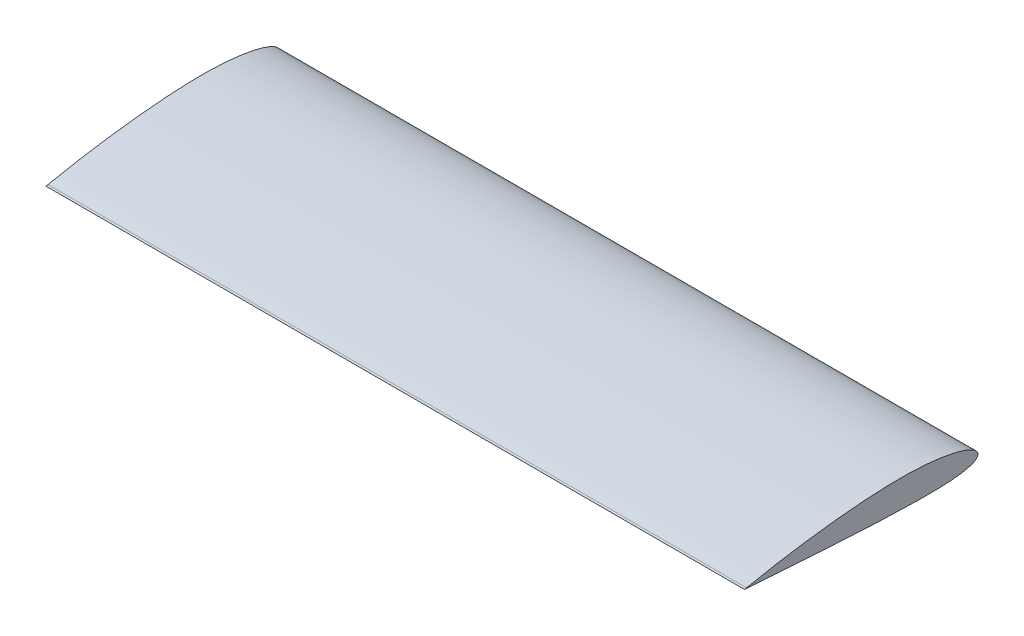
from build123d import *

# Parameters (mm, degrees)
BOSS_EXTRUDE1_DEPTH = 400


with BuildPart() as part:
    # Sketch1 → Boss-Extrude1 (new body, symmetric)
    with BuildSketch(Plane(origin=(0, 0, 0), x_dir=(0, 0, -1), z_dir=(1, 0, 0))):
        with BuildLine():
            Line((-265.02226, 0.333105), (-267.381756582, -0.158412694))
            Line((-267.381756582, -0.158412694), (-264.97774, -0.333105))
            add(Edge.make_bspline(
                [(-265.02226, 0.333105), (-264.887376701, 0.361203167), (-264.348608843, 0.473436402), (-263.139373937, 0.724422494), (-261.13175, 1.137526355), (-258.337172417, 1.704607814), (-254.77214836, 2.41628191), (-250.457262183, 3.259289619), (-245.417849169, 4.219087105), (-239.683580205, 5.280076642), (-233.288212255, 6.424196883), (-226.269957295, 7.633629815), (-218.670630042, 8.890069764), (-210.535821316, 10.174181337), (-201.914571502, 11.467071445), (-192.859315617, 12.750171896), (-183.425101929, 14.004248304), (-173.669610491, 15.210745028), (-163.652758489, 16.352405033), (-153.436223744, 17.409248243), (-143.083389014, 18.36591166), (-132.658565599, 19.203086616), (-122.226992545, 19.907089949), (-111.842174889, 20.461271061), (-101.553936183, 20.858430603), (-91.425655621, 21.025521828), (-81.536046791, 20.961226395), (-71.965550437, 20.664062236), (-62.777430291, 20.137628463), (-54.032464252, 19.389752881), (-45.788026858, 18.433590891), (-38.097997769, 17.285191603), (-31.011682065, 15.96487512), (-24.57391526, 14.495029451), (-18.823561114, 12.902000752), (-13.794651419, 11.21039181), (-9.513772463, 9.447073758), (-6.000885385, 7.635517602), (-3.264749076, 5.79370516), (-1.306921014, 3.92547996), (-0.128663517, 1.993694538), (0.151086197, -0.015132607), (-0.520044606, -1.927078765), (-2.04519397, -3.589289613), (-4.308102643, -5.044738082), (-7.308031355, -6.340715102), (-11.039960644, -7.483835955), (-15.488266155, -8.475389165), (-20.628626587, -9.312853368), (-26.430792204, -9.9954763), (-32.859957453, -10.524354158), (-39.877777854, -10.90395114), (-47.442938194, -11.140321093), (-55.511340396, -11.243311258), (-64.036529176, -11.224101011), (-72.969697841, -11.09793259), (-82.259968207, -10.880177194), (-91.854470541, -10.589734498), (-101.7136957, -10.241908407), (-111.792756577, -9.86098005), (-122.029645296, -9.400323898), (-132.347464274, -8.882997589), (-142.671807574, -8.320275087), (-152.940024856, -7.728145366), (-163.089417584, -7.117374594), (-173.057713445, -6.499887188), (-182.783440418, -5.883594127), (-192.20649845, -5.277169282), (-201.268312633, -4.687108302), (-209.912313525, -4.118405006), (-218.084219069, -3.576286916), (-225.73261747, -3.0636375), (-232.809108358, -2.585576089), (-239.268728848, -2.144484612), (-245.070197097, -1.74457804), (-250.176374287, -1.388736042), (-254.554402568, -1.080359835), (-258.175971421, -0.823254103), (-261.017524089, -0.619491603), (-263.060588228, -0.472447332), (-264.291745446, -0.382954062), (-264.840381648, -0.343086398), (-264.97774, -0.333105)],
                knots=[0, 0, 0, 0, 0.000764172, 0.003052354, 0.006849806, 0.012132473, 0.018867992, 0.027012839, 0.036516812, 0.047320748, 0.059356871, 0.072550805, 0.086820052, 0.102077398, 0.118227703, 0.135170889, 0.152802297, 0.171012918, 0.18968989, 0.20871821, 0.227978895, 0.247353901, 0.266722825, 0.285966043, 0.30503218, 0.323824437, 0.342143817, 0.359879711, 0.376925818, 0.393181853, 0.408552719, 0.422951453, 0.436298149, 0.448522824, 0.459565428, 0.469379445, 0.477933616, 0.485220338, 0.491267538, 0.496167824, 0.50013339, 0.503587222, 0.507040597, 0.511000028, 0.515876125, 0.521872239, 0.529071215, 0.537494991, 0.547131181, 0.557945451, 0.569889642, 0.582904388, 0.596921672, 0.611866369, 0.627656322, 0.64420424, 0.661417059, 0.679197208, 0.697442956, 0.716133923, 0.735139063, 0.75427754, 0.773432072, 0.792486537, 0.811323416, 0.82982615, 0.847880344, 0.865374073, 0.882198025, 0.89824695, 0.913420544, 0.927622056, 0.940762976, 0.952758838, 0.963532927, 0.973016418, 0.981148268, 0.987875252, 0.99315353, 0.996949037, 0.999236151, 1, 1, 1, 1], degree=3))
        make_face()
    extrude(amount=BOSS_EXTRUDE1_DEPTH, both=True)


solid = part.part
